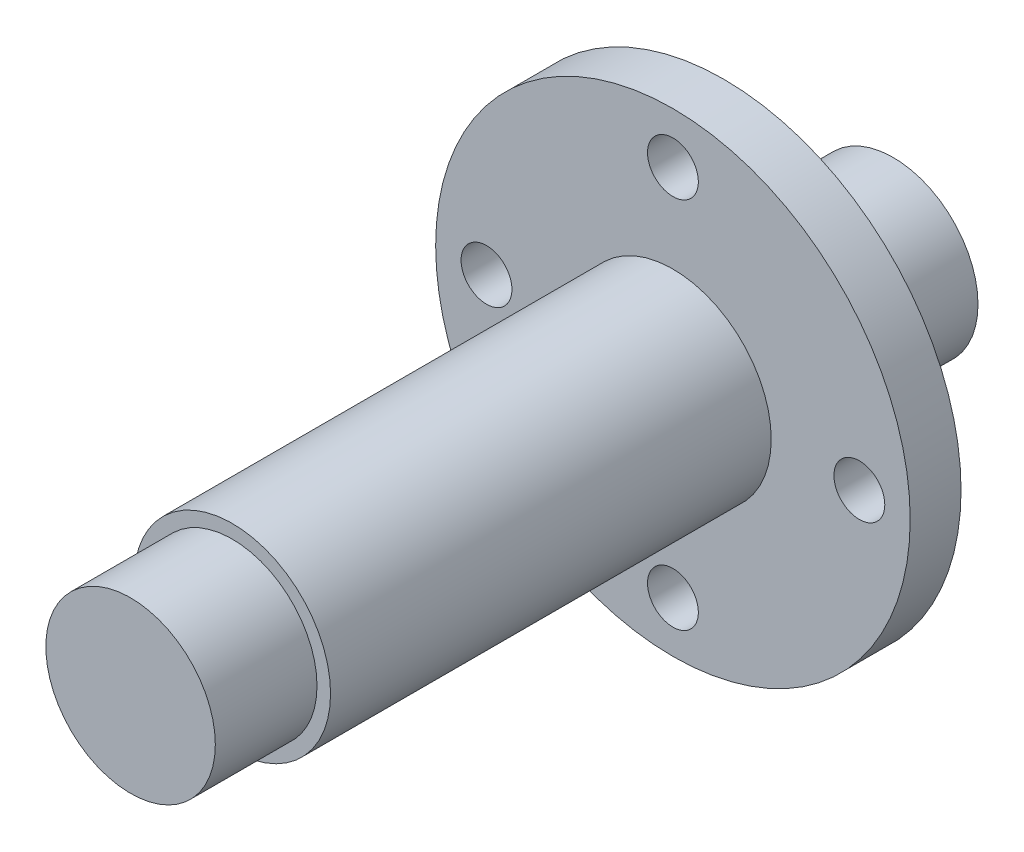
from build123d import *

# Parameters (mm, degrees)
CROQUIS1_R              = 5
SALIENTE_EXTRUIR1_DEPTH = 6
CROQUIS2_R              = 5.8
SALIENTE_EXTRUIR2_DEPTH = 4
CROQUIS3_R              = 14
SALIENTE_EXTRUIR3_DEPTH = 3
CROQUIS4_R              = 5.8
SALIENTE_EXTRUIR4_DEPTH = 26
CROQUIS5_R              = 5
SALIENTE_EXTRUIR5_DEPTH = 6
CROQUIS6_R              = 1.5
CORTAR_EXTRUIR1_DEPTH   = 6


with BuildPart() as part:
    # Croquis1 → Saliente-Extruir1 (new body)
    with BuildSketch(Plane.XY):
        Circle(CROQUIS1_R)
    extrude(amount=SALIENTE_EXTRUIR1_DEPTH)

    # Croquis2 → Saliente-Extruir2 (add)
    with BuildSketch(Plane.XY.offset(6)):
        Circle(CROQUIS2_R)
    extrude(amount=SALIENTE_EXTRUIR2_DEPTH)

    # Croquis3 → Saliente-Extruir3 (add)
    with BuildSketch(Plane.XY.offset(10)):
        Circle(CROQUIS3_R)
    extrude(amount=SALIENTE_EXTRUIR3_DEPTH)

    # Croquis4 → Saliente-Extruir4 (add)
    with BuildSketch(Plane.XY.offset(13)):
        Circle(CROQUIS4_R)
    extrude(amount=SALIENTE_EXTRUIR4_DEPTH)

    # Croquis5 → Saliente-Extruir5 (add)
    with BuildSketch(Plane.XY.offset(39)):
        Circle(CROQUIS5_R)
    extrude(amount=SALIENTE_EXTRUIR5_DEPTH)

    # Croquis6 → Cortar-Extruir1 (cut)
    with BuildSketch(Plane(origin=(0, 0, 10), x_dir=(-1, 0, 0), z_dir=(0, 0, -1))):
        with Locations((11, 0)):
            Circle(CROQUIS6_R)
        with Locations((0, -11)):
            Circle(CROQUIS6_R)
        with Locations((-11, 0)):
            Circle(CROQUIS6_R)
        with Locations((0, 11)):
            Circle(CROQUIS6_R)
    extrude(amount=-CORTAR_EXTRUIR1_DEPTH, mode=Mode.SUBTRACT)


solid = part.part
